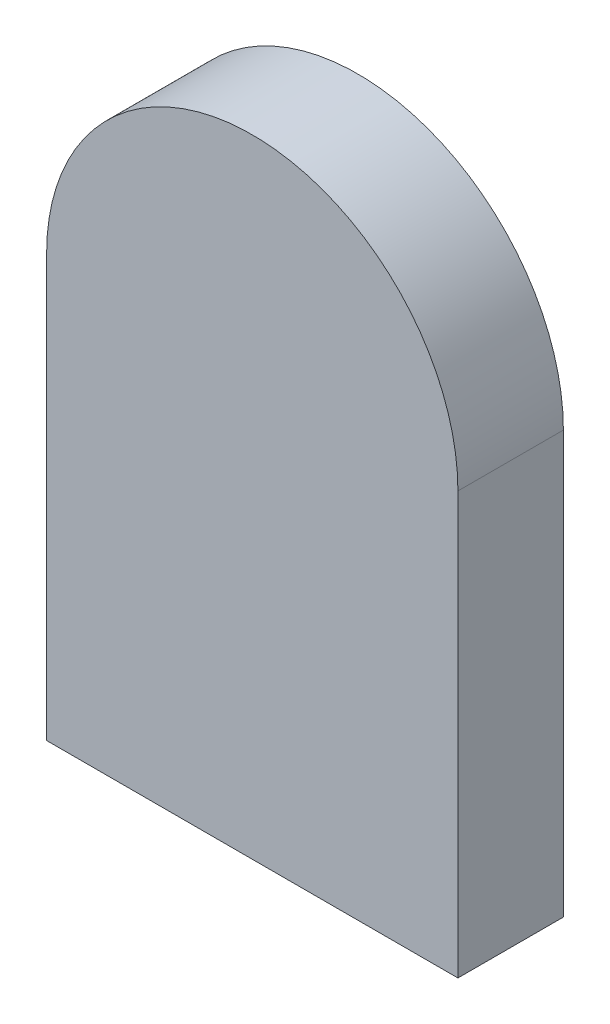
from build123d import *

# Parameters (mm, degrees)
SALIENTE_EXTRUIR1_DEPTH = 1
SALIENTE_EXTRUIR2_DEPTH = 1


with BuildPart() as part:
    # Croquis1 → Saliente-Extruir1 (new body)
    with BuildSketch(Plane.XY):
        with BuildLine():
            Line((-77.34358908, -6.813189194), (-77.34358908, 0.186810806))
            ThreePointArc((-77.34358908, 0.186810806), (-74.44358908, 3.086810806), (-71.54358908, 0.186810806))
            Line((-71.54358908, 0.186810806), (-71.54358908, -6.813189194))
            Line((-71.54358908, -6.813189194), (-71.54358908, -7.813189194))
            Line((-71.54358908, -7.813189194), (-70.54358908, -7.813189194))
            Line((-70.54358908, -7.813189194), (-70.54358908, 0.185713536))
            ThreePointArc((-70.54358908, 0.185713536), (-74.44358908, 4.085713536), (-78.34358908, 0.185713536))
            Line((-78.34358908, 0.185713536), (-78.34358908, -7.813189194))
            Line((-78.34358908, -7.813189194), (-77.34358908, -7.813189194))
            Line((-77.34358908, -7.813189194), (-77.34358908, -6.813189194))
        make_face()
    extrude(amount=SALIENTE_EXTRUIR1_DEPTH)

    # Croquis3 → Saliente-Extruir2 (add)
    with BuildSketch(Plane.XY.offset(1)):
        with BuildLine():
            Line((-77.34358908, -7.813189194), (-78.34358908, -7.813189194))
            Line((-78.34358908, -7.813189194), (-78.34358908, 0.185713536))
            ThreePointArc((-78.34358908, 0.185713536), (-74.44358908, 4.085713536), (-70.54358908, 0.185713536))
            Line((-70.54358908, 0.185713536), (-70.54358908, -7.813189194))
            Line((-70.54358908, -7.813189194), (-77.34358908, -7.813189194))
        make_face()
    extrude(amount=SALIENTE_EXTRUIR2_DEPTH)


solid = part.part
